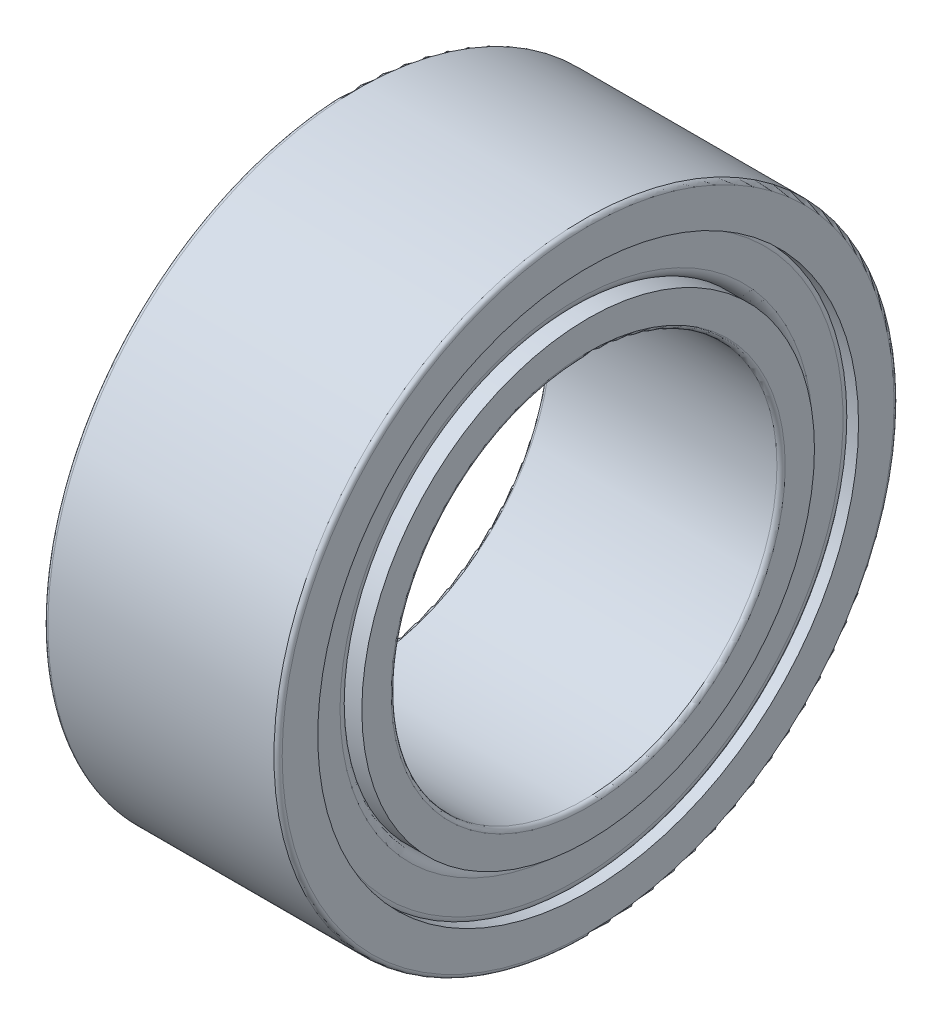
from build123d import *


with BuildPart() as part:
    # OutRacSke → OuterRace (revolve)
    with BuildSketch(Plane.XY):
        with BuildLine():
            Line((-7.65, 20.0775), (-7.65, 19.620625))
            Line((-7.65, 19.620625), (-8.5, 19.620625))
            Line((-8.5, 19.620625), (-8.5, 22.2))
            ThreePointArc((-8.5, 22.2), (-8.412132034, 22.412132034), (-8.2, 22.5))
            Line((-8.2, 22.5), (8.2, 22.5))
            ThreePointArc((8.2, 22.5), (8.412132034, 22.412132034), (8.5, 22.2))
            Line((8.5, 22.2), (8.5, 19.620625))
            Line((8.5, 19.620625), (7.65, 19.620625))
            Line((7.65, 19.620625), (7.65, 20.0775))
            Line((7.65, 20.0775), (-7.65, 20.0775))
        make_face()
    revolve(axis=Axis((-7.9375, 0, 0), (1, 0, 0)))

    # RolSimSke → RollersSimplified (revolve)
    with BuildSketch(Plane(origin=(0, 25.4, 0), x_dir=(1, 0, 0), z_dir=(0, 0, 1))):
        with BuildLine():
            Line((-7.65, -6.0527), (-7.65, -8.2463))
            ThreePointArc((-7.65, -8.2463), (-7.435836478, -8.763336478), (-6.9188, -8.9775))
            Line((-6.9188, -8.9775), (6.9188, -8.9775))
            ThreePointArc((6.9188, -8.9775), (7.435836478, -8.763336478), (7.65, -8.2463))
            Line((7.65, -8.2463), (7.65, -6.0527))
            ThreePointArc((7.65, -6.0527), (7.435836478, -5.535663522), (6.9188, -5.3215))
            Line((6.9188, -5.3215), (-6.9188, -5.3215))
            ThreePointArc((-6.9188, -5.3215), (-7.435836478, -5.535663522), (-7.65, -6.0527))
        make_face()
    revolve(axis=Axis((-25.4, 0, 0), (1, 0, 0)))

    # InsRacSke → InnerRace (revolve)
    with BuildSketch(Plane.XY):
        with BuildLine():
            Line((-8.5, 16.4225), (-8.5, 14.3))
            ThreePointArc((-8.5, 14.3), (-8.412132034, 14.087867966), (-8.2, 14))
            Line((-8.2, 14), (8.2, 14))
            ThreePointArc((8.2, 14), (8.412132034, 14.087867966), (8.5, 14.3))
            Line((8.5, 14.3), (8.5, 16.4225))
            Line((8.5, 16.4225), (-8.5, 16.4225))
        make_face()
    revolve(axis=Axis((-7.9375, 0, 0), (1, 0, 0)))


solid = part.part
